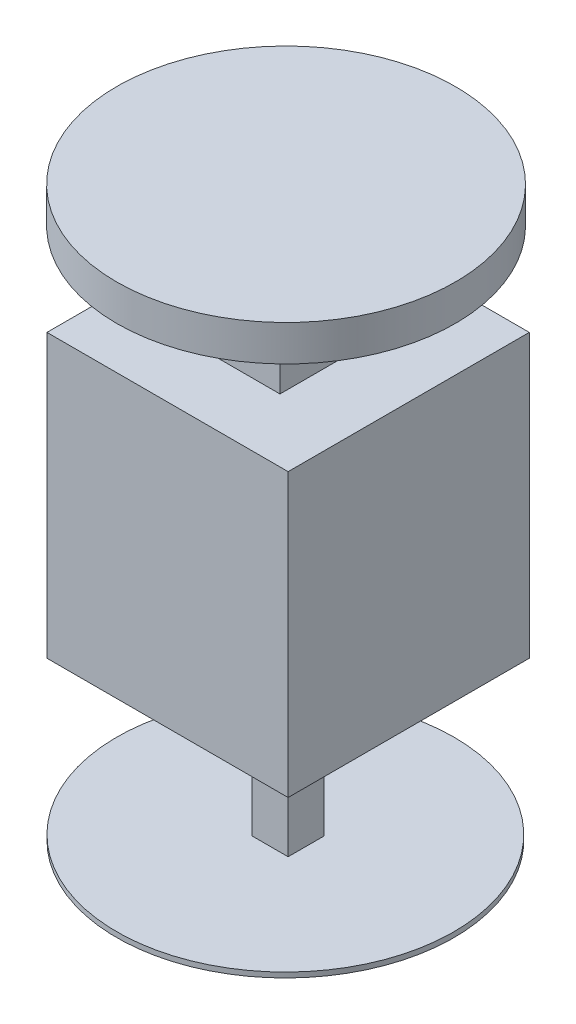
from build123d import *

# Parameters (mm, degrees)
SKETCH1_W           = 47
SKETCH1_H           = 47
BOSS_EXTRUDE1_DEPTH = 85
SKETCH2_W           = 47
SKETCH2_H           = 30
CUT_EXTRUDE1_DEPTH  = 20
SKETCH3_W           = 27
SKETCH3_H           = 29.949158553
CUT_EXTRUDE2_DEPTH  = 20
SKETCH4_W           = 27
SKETCH4_H           = 30
CUT_EXTRUDE3_DEPTH  = 20
SKETCH5_W           = 7
SKETCH5_H           = 30
CUT_EXTRUDE4_DEPTH  = 20
SKETCH6_W           = 17.880231582
SKETCH6_H           = 18.920879981
BOSS_EXTRUDE2_DEPTH = 18
SKETCH7_R           = 33
BOSS_EXTRUDE4_DEPTH = 7
SKETCH9_R           = 32.855450218
BOSS_EXTRUDE5_DEPTH = 1


with BuildPart() as part:
    # Sketch1 → Boss-Extrude1 (new body)
    with BuildSketch(Plane(origin=(0, 0, 0), x_dir=(1, 0, 0), z_dir=(0, 1, 0))):
        with Locations((23.5, 23.5)):
            Rectangle(SKETCH1_W, SKETCH1_H)
    extrude(amount=BOSS_EXTRUDE1_DEPTH)

    # Sketch2 → Cut-Extrude1 (cut)
    with BuildSketch(Plane.XY):
        with Locations((23.5, 15)):
            Rectangle(SKETCH2_W, SKETCH2_H)
    extrude(amount=-CUT_EXTRUDE1_DEPTH, mode=Mode.SUBTRACT)

    # Sketch3 → Cut-Extrude2 (cut)
    with BuildSketch(Plane.ZY):
        with Locations((-33.5, 14.974579277)):
            Rectangle(SKETCH3_W, SKETCH3_H)
    extrude(amount=-CUT_EXTRUDE2_DEPTH, mode=Mode.SUBTRACT)

    # Sketch4 → Cut-Extrude3 (cut)
    with BuildSketch(Plane(origin=(0, 0, -47), x_dir=(-1, 0, 0), z_dir=(0, 0, -1))):
        with Locations((-33.5, 15)):
            Rectangle(SKETCH4_W, SKETCH4_H)
    extrude(amount=-CUT_EXTRUDE3_DEPTH, mode=Mode.SUBTRACT)

    # Sketch5 → Cut-Extrude4 (cut)
    with BuildSketch(Plane(origin=(47, 0, 0), x_dir=(0, 0, -1), z_dir=(1, 0, 0))):
        with Locations((23.5, 15)):
            Rectangle(SKETCH5_W, SKETCH5_H)
    extrude(amount=-CUT_EXTRUDE4_DEPTH, mode=Mode.SUBTRACT)

    # Sketch6 → Boss-Extrude2 (add)
    with BuildSketch(Plane(origin=(0, 85, 0), x_dir=(1, 0, 0), z_dir=(0, 1, 0))):
        with Locations((24.162230799, 21.773469702)):
            Rectangle(SKETCH6_W, SKETCH6_H)
    extrude(amount=BOSS_EXTRUDE2_DEPTH)

    # Sketch7 → Boss-Extrude4 (add)
    with BuildSketch(Plane(origin=(0, 103, 0), x_dir=(1, 0, 0), z_dir=(0, 1, 0))):
        with Locations((23.29896565, 23.29896565)):
            Circle(SKETCH7_R)
    extrude(amount=BOSS_EXTRUDE4_DEPTH)

    # Sketch9 → Boss-Extrude5 (add)
    with BuildSketch(Plane.XZ):
        with Locations((22.961502761, -23.5)):
            Circle(SKETCH9_R)
    extrude(amount=BOSS_EXTRUDE5_DEPTH)


solid = part.part
